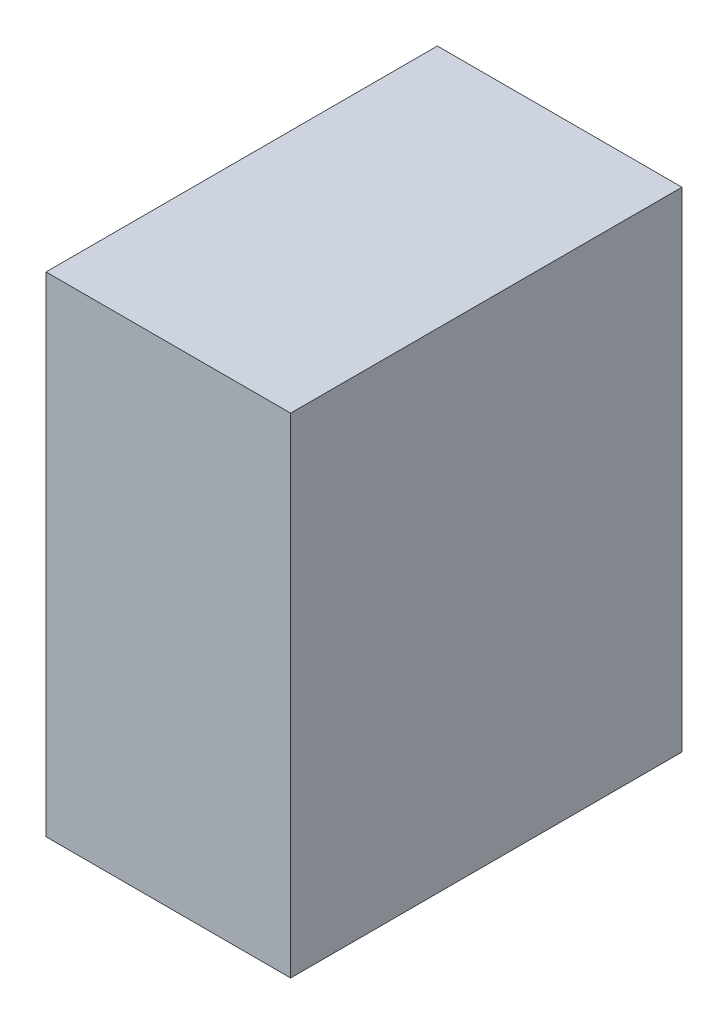
from build123d import *

# Parameters (mm, degrees)
SKETCH1_W           = 50
SKETCH1_H           = 100
BOSS_EXTRUDE1_DEPTH = 80


with BuildPart() as part:
    # Sketch1 → Boss-Extrude1 (new body)
    with BuildSketch(Plane.XY):
        with Locations((-25, 3.618421053)):
            Rectangle(SKETCH1_W, SKETCH1_H)
    extrude(amount=BOSS_EXTRUDE1_DEPTH)


solid = part.part
